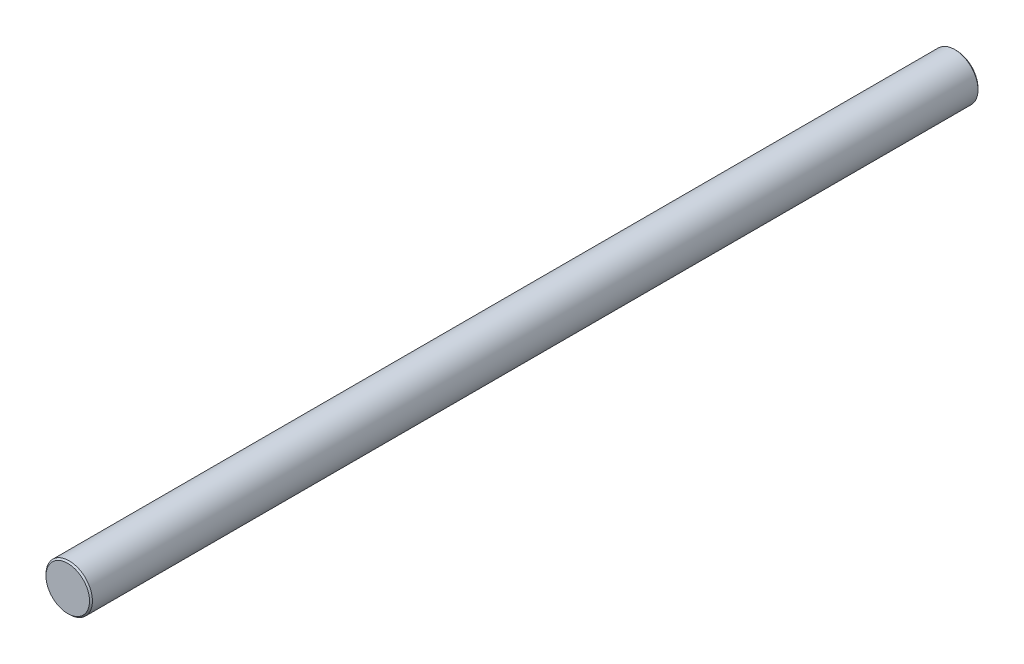
from build123d import *

# Parameters (mm, degrees)
SKETCH1_R           = 8
BOSS_EXTRUDE1_DEPTH = 306
CHAMFER1_SIZE       = 0.5


with BuildPart() as part:
    # Sketch1 → Boss-Extrude1 (new body)
    with BuildSketch(Plane.XY):
        Circle(SKETCH1_R)
    extrude(amount=BOSS_EXTRUDE1_DEPTH)

    # Chamfer1
    chamfer1_edges = [part.edges().sort_by_distance(p)[0] for p in [
        (-8, 0, 0),
        (-8, 0, 306),
    ]]
    chamfer(chamfer1_edges, length=CHAMFER1_SIZE)


solid = part.part
